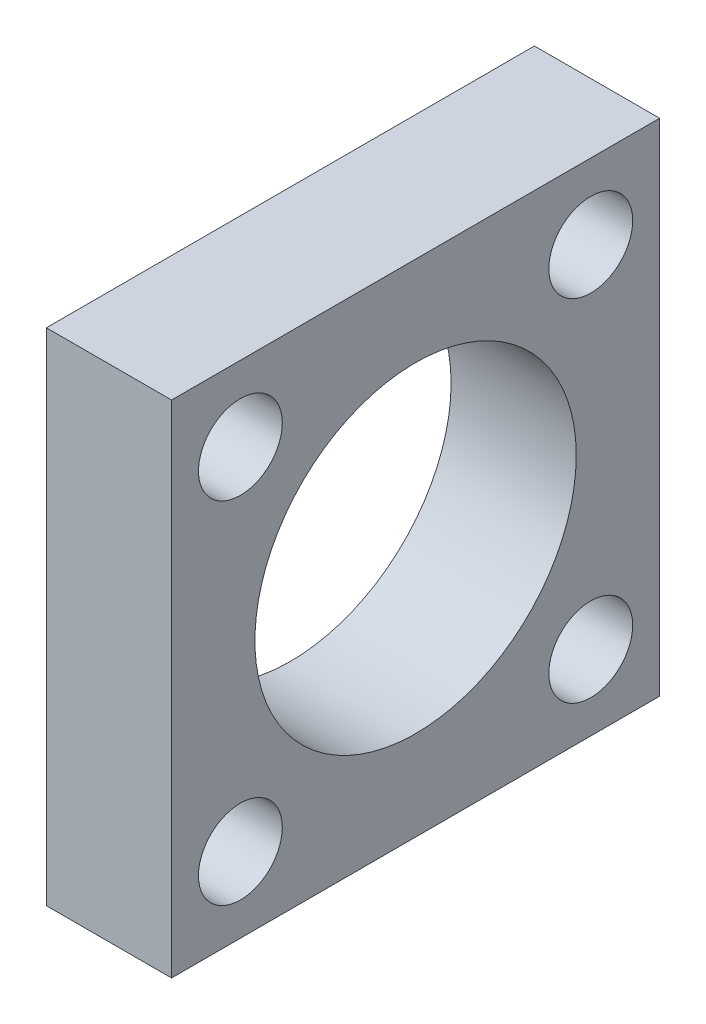
from build123d import *

# Parameters (mm, degrees)
SKETCH1_W                       = 39
SKETCH1_H                       = 40
BOSS_EXTRUDE1_DEPTH             = 10
SM1_THREADED_HOLE_REACH         = 40.282
SKETCH1_3_R                     = 12.8397
OVERSIZED_8_32_THRU_HOLES_REACH = 40.282
SKETCH1_4_R                     = 3.35
F_8_32_TAPPED_HOLE1_D           = 3.4544
F_8_32_TAPPED_HOLE1_DEPTH       = 6
F_8_32_TAPPED_HOLE1_TIP         = 1.037806461


with BuildPart() as part:
    # Sketch1 → Boss-Extrude1 (new body)
    with BuildSketch(Plane(origin=(0, 0, 0), x_dir=(0, 0, -1), z_dir=(1, 0, 0))):
        with Locations((3.409258695, -8.993814604)):
            Rectangle(SKETCH1_W, SKETCH1_H)
    extrude(amount=BOSS_EXTRUDE1_DEPTH)

    # Sketch1_3 → SM1 threaded hole (cut, up to next)
    with BuildSketch(Plane(origin=(0, 0, 0), x_dir=(0, 0, -1), z_dir=(1, 0, 0)), mode=Mode.PRIVATE) as sm1_threaded_hole_sk1:
        with Locations((3.409258695, -8.993814604)):
            Circle(SKETCH1_3_R)
    sm1_threaded_hole_tool1 = extrude(sm1_threaded_hole_sk1.sketch, amount=SM1_THREADED_HOLE_REACH, mode=Mode.PRIVATE) & part.part
    add(sm1_threaded_hole_tool1.solids().sort_by_distance((0, -8.993815, -3.409259))[0], mode=Mode.SUBTRACT)

    # Sketch1_4 → oversized 8-32 thru holes (cut, up to next)
    with BuildSketch(Plane(origin=(0, 0, 0), x_dir=(0, 0, -1), z_dir=(1, 0, 0)), mode=Mode.PRIVATE) as oversized_8_32_thru_holes_sk1:
        with Locations((-10.590741305, 5.006185396)):
            Circle(SKETCH1_4_R)
    oversized_8_32_thru_holes_tool1 = extrude(oversized_8_32_thru_holes_sk1.sketch, amount=OVERSIZED_8_32_THRU_HOLES_REACH, mode=Mode.PRIVATE) & part.part
    # Sketch1_4 → oversized 8-32 thru holes (cut, up to next)
    with BuildSketch(Plane(origin=(0, 0, 0), x_dir=(0, 0, -1), z_dir=(1, 0, 0)), mode=Mode.PRIVATE) as oversized_8_32_thru_holes_sk2:
        with Locations((17.409258695, 5.006185396)):
            Circle(SKETCH1_4_R)
    oversized_8_32_thru_holes_tool2 = extrude(oversized_8_32_thru_holes_sk2.sketch, amount=OVERSIZED_8_32_THRU_HOLES_REACH, mode=Mode.PRIVATE) & part.part
    # Sketch1_4 → oversized 8-32 thru holes (cut, up to next)
    with BuildSketch(Plane(origin=(0, 0, 0), x_dir=(0, 0, -1), z_dir=(1, 0, 0)), mode=Mode.PRIVATE) as oversized_8_32_thru_holes_sk3:
        with Locations((17.409258695, -22.993814604)):
            Circle(SKETCH1_4_R)
    oversized_8_32_thru_holes_tool3 = extrude(oversized_8_32_thru_holes_sk3.sketch, amount=OVERSIZED_8_32_THRU_HOLES_REACH, mode=Mode.PRIVATE) & part.part
    # Sketch1_4 → oversized 8-32 thru holes (cut, up to next)
    with BuildSketch(Plane(origin=(0, 0, 0), x_dir=(0, 0, -1), z_dir=(1, 0, 0)), mode=Mode.PRIVATE) as oversized_8_32_thru_holes_sk4:
        with Locations((-10.590741305, -22.993814604)):
            Circle(SKETCH1_4_R)
    oversized_8_32_thru_holes_tool4 = extrude(oversized_8_32_thru_holes_sk4.sketch, amount=OVERSIZED_8_32_THRU_HOLES_REACH, mode=Mode.PRIVATE) & part.part
    add(oversized_8_32_thru_holes_tool1.solids().sort_by_distance((0, 5.006185, 10.590741))[0], mode=Mode.SUBTRACT)
    add(oversized_8_32_thru_holes_tool2.solids().sort_by_distance((0, 5.006185, -17.409259))[0], mode=Mode.SUBTRACT)
    add(oversized_8_32_thru_holes_tool3.solids().sort_by_distance((0, -22.993815, -17.409259))[0], mode=Mode.SUBTRACT)
    add(oversized_8_32_thru_holes_tool4.solids().sort_by_distance((0, -22.993815, 10.590741))[0], mode=Mode.SUBTRACT)

    # 8-32 Tapped Hole1
    with Locations(Plane(origin=(0, -28.993814604, 0), x_dir=(-1, 0, 0), z_dir=(0, -1, 0))):
        with Locations((-5, 9.909258695)):
            Hole(F_8_32_TAPPED_HOLE1_D / 2, depth=F_8_32_TAPPED_HOLE1_DEPTH)
            with Locations((0, 0, -(F_8_32_TAPPED_HOLE1_DEPTH + F_8_32_TAPPED_HOLE1_TIP / 2))):  # 118° drill point
                Cone(0, F_8_32_TAPPED_HOLE1_D / 2, F_8_32_TAPPED_HOLE1_TIP, mode=Mode.SUBTRACT)


solid = part.part
